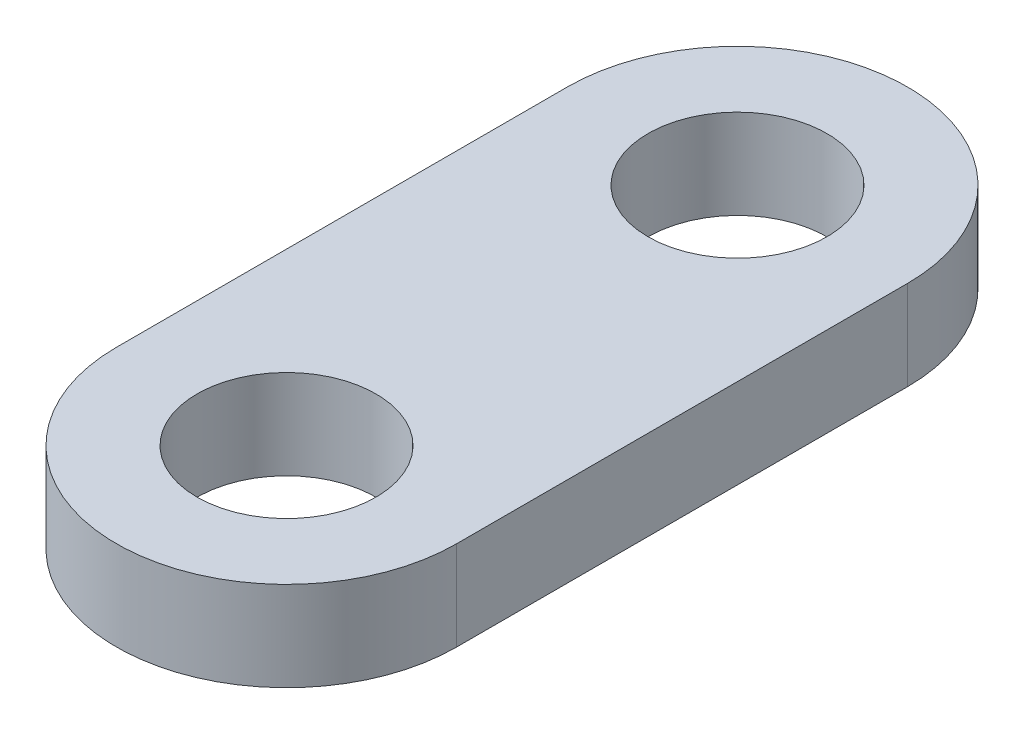
from build123d import *

# Parameters (mm, degrees)
SKETCH1_R           = 2.5
BOSS_EXTRUDE1_DEPTH = 2.5


with BuildPart() as part:
    # Sketch1 → Boss-Extrude1 (new body)
    with BuildSketch(Plane(origin=(0, 0, 0), x_dir=(1, 0, 0), z_dir=(0, 1, 0))):
        with BuildLine():
            Line((4.752927956, 6.578761062), (4.752927956, -6.021238938))
            ThreePointArc((4.752927956, -6.021238938), (0, -10.774166894), (-4.752927956, -6.021238938))
            Line((-4.752927956, -6.021238938), (-4.752927956, 6.578761062))
            ThreePointArc((-4.752927956, 6.578761062), (0, 11.331689018), (4.752927956, 6.578761062))
        make_face()
        with Locations((0, 6.578761062)):
            Circle(SKETCH1_R, mode=Mode.SUBTRACT)
        with Locations((0, -6.021238938)):
            Circle(SKETCH1_R, mode=Mode.SUBTRACT)
    extrude(amount=BOSS_EXTRUDE1_DEPTH)


solid = part.part
